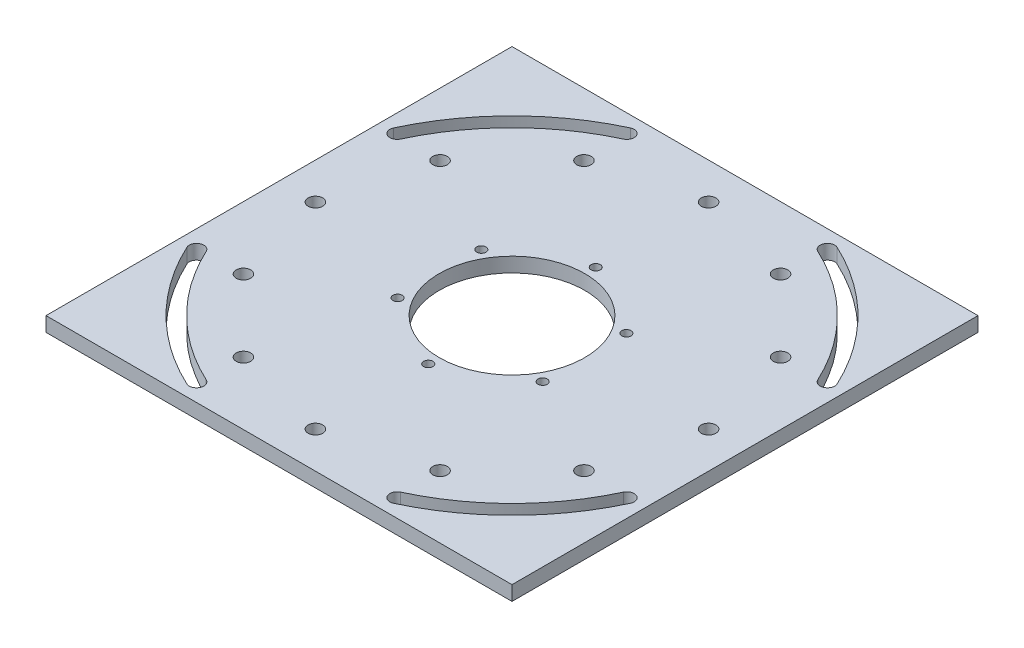
from build123d import *

# Parameters (mm, degrees)
SKETCH1_W                       = 203.2
SKETCH1_H                       = 203.2
BOSS_EXTRUDE1_DEPTH             = 6.35
CUT_EXTRUDE1_REACH              = 8.35
SKETCH2_R                       = 31.75
F_1_4_0_25_DIAMETER_HOLE1_D     = 6.35
F_1_4_0_25_DIAMETER_HOLE1_DEPTH = 6.351
CIRPATTERN1_COUNT               = 12
F_10_32_TAPPED_HOLE1_D          = 4.0386
F_10_32_TAPPED_HOLE1_DEPTH      = 6.351
CIRPATTERN2_COUNT               = 6
CUT_EXTRUDE2_REACH              = 8.35


with BuildPart() as part:
    # Sketch1 → Boss-Extrude1 (new body)
    with BuildSketch(Plane(origin=(0, 0, 0), x_dir=(1, 0, 0), z_dir=(0, 1, 0))):
        Rectangle(SKETCH1_W, SKETCH1_H)
    extrude(amount=BOSS_EXTRUDE1_DEPTH)

    # Sketch2 → Cut-Extrude1 (cut, up to next)
    with BuildSketch(Plane(origin=(0, 6.35, 0), x_dir=(1, 0, 0), z_dir=(0, 1, 0)), mode=Mode.PRIVATE) as cut_extrude1_sk1:
        with Locations(Location((0, 0, 0), (0, 0, 270))):  # turned: the seam where the file's is
            Circle(SKETCH2_R)
    cut_extrude1_tool1 = extrude(cut_extrude1_sk1.sketch, amount=-CUT_EXTRUDE1_REACH, mode=Mode.PRIVATE) & part.part
    add(cut_extrude1_tool1.solids().sort_by_distance((0, 6.35, 0))[0], mode=Mode.SUBTRACT)

    # 1/4 (0.25) Diameter Hole1
    with Locations(Plane(origin=(0, 6.35, 0), x_dir=(1, 0, 0), z_dir=(0, 1, 0))):
        with Locations((0, 85.725)):
            f_1_4_0_25_diameter_hole1 = Hole(F_1_4_0_25_DIAMETER_HOLE1_D / 2, depth=F_1_4_0_25_DIAMETER_HOLE1_DEPTH)

    # CirPattern1: 1/4 (0.25) Diameter Hole1 ×12 about axis
    cirpattern1_axis = Axis((0, 0, 0), (0, 1, 0))
    for i in range(1, CIRPATTERN1_COUNT):
        add(f_1_4_0_25_diameter_hole1.rotate(cirpattern1_axis, i * 360 / CIRPATTERN1_COUNT), mode=Mode.SUBTRACT)

    # #10-32 Tapped Hole1
    with Locations(Plane(origin=(0, 6.35, 0), x_dir=(1, 0, 0), z_dir=(0, 1, 0))):
        with Locations((0, 36.5125)):
            f_10_32_tapped_hole1 = Hole(F_10_32_TAPPED_HOLE1_D / 2, depth=F_10_32_TAPPED_HOLE1_DEPTH)

    # CirPattern2: #10-32 Tapped Hole1 ×6 about axis
    cirpattern2_axis = Axis((0, 0, 0), (0, 1, 0))
    for i in range(1, CIRPATTERN2_COUNT):
        add(f_10_32_tapped_hole1.rotate(cirpattern2_axis, i * 360 / CIRPATTERN2_COUNT), mode=Mode.SUBTRACT)

    # Sketch7 → Cut-Extrude2 (cut, up to next)
    with BuildSketch(Plane(origin=(0, 6.35, 0), x_dir=(1, 0, 0), z_dir=(0, 1, 0)), mode=Mode.PRIVATE) as cut_extrude2_sk1:
        with BuildLine():
            ThreePointArc((96.684914721, 45.084916162), (75.434151417, 75.434151417), (45.084916162, 96.684914721))
            ThreePointArc((45.084916162, 96.684914721), (40.865575958, 95.149200478), (42.4012902, 90.929860273))
            ThreePointArc((42.4012902, 90.929860273), (70.944023356, 70.944023356), (90.929860273, 42.4012902))
            ThreePointArc((90.929860273, 42.4012902), (95.149200478, 40.865575958), (96.684914721, 45.084916162))
        make_face()
    cut_extrude2_tool1 = extrude(cut_extrude2_sk1.sketch, amount=-CUT_EXTRUDE2_REACH, mode=Mode.PRIVATE) & part.part
    add(cut_extrude2_tool1.solids().sort_by_distance((71.522214, 6.35, -71.522214))[0], mode=Mode.SUBTRACT)
    # Sketch7 → Cut-Extrude2 (cut, up to next)
    with BuildSketch(Plane(origin=(0, 6.35, 0), x_dir=(1, 0, 0), z_dir=(0, 1, 0)), mode=Mode.PRIVATE) as cut_extrude2_sk2:
        with BuildLine():
            ThreePointArc((45.084916162, -96.684914721), (75.434151417, -75.434151417), (96.684914721, -45.084916162))
            ThreePointArc((96.684914721, -45.084916162), (95.149200478, -40.865575958), (90.929860273, -42.4012902))
            ThreePointArc((90.929860273, -42.4012902), (70.944023356, -70.944023356), (42.4012902, -90.929860273))
            ThreePointArc((42.4012902, -90.929860273), (40.865575958, -95.149200478), (45.084916162, -96.684914721))
        make_face()
    cut_extrude2_tool2 = extrude(cut_extrude2_sk2.sketch, amount=-CUT_EXTRUDE2_REACH, mode=Mode.PRIVATE) & part.part
    add(cut_extrude2_tool2.solids().sort_by_distance((71.522214, 6.35, 71.522214))[0], mode=Mode.SUBTRACT)
    # Sketch7 → Cut-Extrude2 (cut, up to next)
    with BuildSketch(Plane(origin=(0, 6.35, 0), x_dir=(1, 0, 0), z_dir=(0, 1, 0)), mode=Mode.PRIVATE) as cut_extrude2_sk3:
        with BuildLine():
            ThreePointArc((-96.684914721, -45.084916162), (-75.434151417, -75.434151417), (-45.084916162, -96.684914721))
            ThreePointArc((-45.084916162, -96.684914721), (-40.865575958, -95.149200478), (-42.4012902, -90.929860273))
            ThreePointArc((-42.4012902, -90.929860273), (-70.944023356, -70.944023356), (-90.929860273, -42.4012902))
            ThreePointArc((-90.929860273, -42.4012902), (-95.149200478, -40.865575958), (-96.684914721, -45.084916162))
        make_face()
    cut_extrude2_tool3 = extrude(cut_extrude2_sk3.sketch, amount=-CUT_EXTRUDE2_REACH, mode=Mode.PRIVATE) & part.part
    add(cut_extrude2_tool3.solids().sort_by_distance((-71.522214, 6.35, 71.522214))[0], mode=Mode.SUBTRACT)
    # Sketch7 → Cut-Extrude2 (cut, up to next)
    with BuildSketch(Plane(origin=(0, 6.35, 0), x_dir=(1, 0, 0), z_dir=(0, 1, 0)), mode=Mode.PRIVATE) as cut_extrude2_sk4:
        with BuildLine():
            ThreePointArc((-45.084916162, 96.684914721), (-75.434151417, 75.434151417), (-96.684914721, 45.084916162))
            ThreePointArc((-96.684914721, 45.084916162), (-95.149200478, 40.865575958), (-90.929860273, 42.4012902))
            ThreePointArc((-90.929860273, 42.4012902), (-70.944023356, 70.944023356), (-42.4012902, 90.929860273))
            ThreePointArc((-42.4012902, 90.929860273), (-40.865575958, 95.149200478), (-45.084916162, 96.684914721))
        make_face()
    cut_extrude2_tool4 = extrude(cut_extrude2_sk4.sketch, amount=-CUT_EXTRUDE2_REACH, mode=Mode.PRIVATE) & part.part
    add(cut_extrude2_tool4.solids().sort_by_distance((-71.522214, 6.35, -71.522214))[0], mode=Mode.SUBTRACT)


solid = part.part
